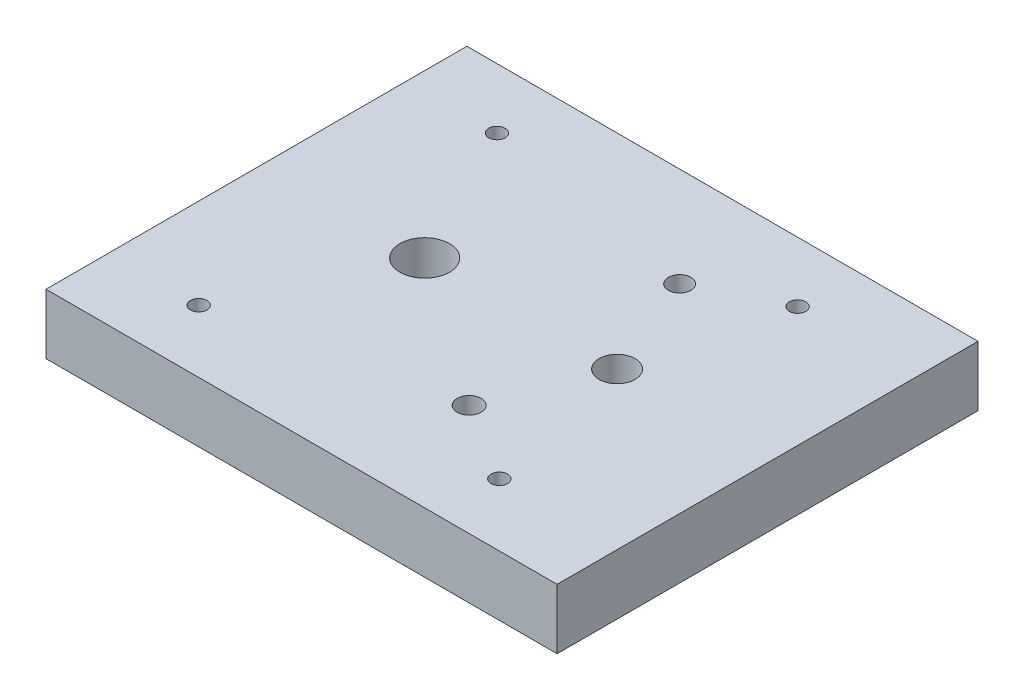
from build123d import *

# Parameters (mm, degrees)
SKETCH1_W           = 85
SKETCH1_H           = 70
SKETCH1_R           = 1.375
SKETCH1_R_2         = 2
SKETCH1_R_3         = 1.875
SKETCH1_R_4         = 4.125
SKETCH1_R_5         = 3
BOSS_EXTRUDE4_DEPTH = 10
SKETCH1_7_R         = 4.5
CUT_EXTRUDE2_DEPTH  = 2


with BuildPart() as part:
    # Sketch1 → Boss-Extrude4 (new body)
    with BuildSketch(Plane(origin=(0, 0, 0), x_dir=(1, 0, 0), z_dir=(0, 1, 0))):
        Rectangle(SKETCH1_W, SKETCH1_H)
        with Locations((-27.5, -24.60667729)):
            Circle(SKETCH1_R, mode=Mode.SUBTRACT)
        with Locations((22.5, -24.60667729)):
            Circle(SKETCH1_R, mode=Mode.SUBTRACT)
        with Locations((9.401398241, -16.528956449)):
            Circle(SKETCH1_R_2, mode=Mode.SUBTRACT)
        with Locations((-27.5, 25)):
            Circle(SKETCH1_R, mode=Mode.SUBTRACT)
        with Locations((9.407211052, 18.471043068)):
            Circle(SKETCH1_R_3, mode=Mode.SUBTRACT)
        with Locations((22.5, 25)):
            Circle(SKETCH1_R, mode=Mode.SUBTRACT)
        with Locations((-15.52, 1)):
            Circle(SKETCH1_R_4, mode=Mode.SUBTRACT)
        with Locations((16.478339488, 0.999882702)):
            Circle(SKETCH1_R_5, mode=Mode.SUBTRACT)
    extrude(amount=BOSS_EXTRUDE4_DEPTH)

    # Sketch1_7 → Cut-Extrude2 (cut)
    with BuildSketch(Plane(origin=(0, 0, 0), x_dir=(1, 0, 0), z_dir=(0, 1, 0))):
        with Locations((16.478339488, 0.999882702)):
            Circle(SKETCH1_7_R)
    extrude(amount=CUT_EXTRUDE2_DEPTH, mode=Mode.SUBTRACT)


solid = part.part
